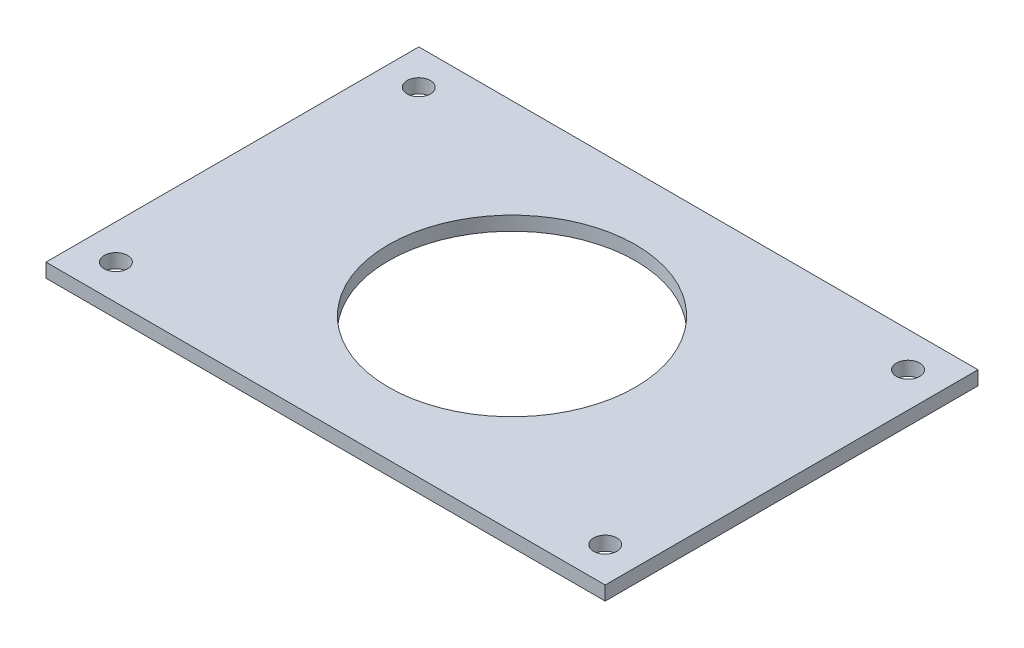
from build123d import *

# Parameters (mm, degrees)
SKETCH1_R                       = 26.5
SKETCH1_W                       = 15
SKETCH1_H                       = 15
BOSS_EXTRUDE1_DEPTH             = 3
TAP_DRILL_FOR_M6X1_0_TAP1_D     = 5
TAP_DRILL_FOR_M6X1_0_TAP1_DEPTH = 3


with BuildPart() as part:
    # Sketch1 → Boss-Extrude1 (new body)
    with BuildSketch(Plane(origin=(0, 0, 0), x_dir=(1, 0, 0), z_dir=(0, 1, 0))):
        Polygon((45, 40), (-45, 40), (-45, 25), (-60, 25), (-60, -25), (-45, -25), (-45, -40), (45, -40), (45, -25), (60, -25), (60, 25), (45, 25), align=None)
        Circle(SKETCH1_R, mode=Mode.SUBTRACT)
        with Locations((52.5, -32.5)):
            Rectangle(SKETCH1_W, SKETCH1_H)
        with Locations((52.5, 32.5)):
            Rectangle(SKETCH1_W, SKETCH1_H)
        with Locations((-52.5, 32.5)):
            Rectangle(SKETCH1_W, SKETCH1_H)
        with Locations((-52.5, -32.5)):
            Rectangle(SKETCH1_W, SKETCH1_H)
    extrude(amount=BOSS_EXTRUDE1_DEPTH)

    # Tap Drill for M6x1.0 Tap1
    with Locations(Plane(origin=(0, 0, 0), x_dir=(-1, 0, 0), z_dir=(0, -1, 0))):
        with Locations((52.5, -32.5), (-52.5, -32.5), (-52.5, 32.5), (52.5, 32.5)):
            Hole(TAP_DRILL_FOR_M6X1_0_TAP1_D / 2, depth=TAP_DRILL_FOR_M6X1_0_TAP1_DEPTH)


solid = part.part
